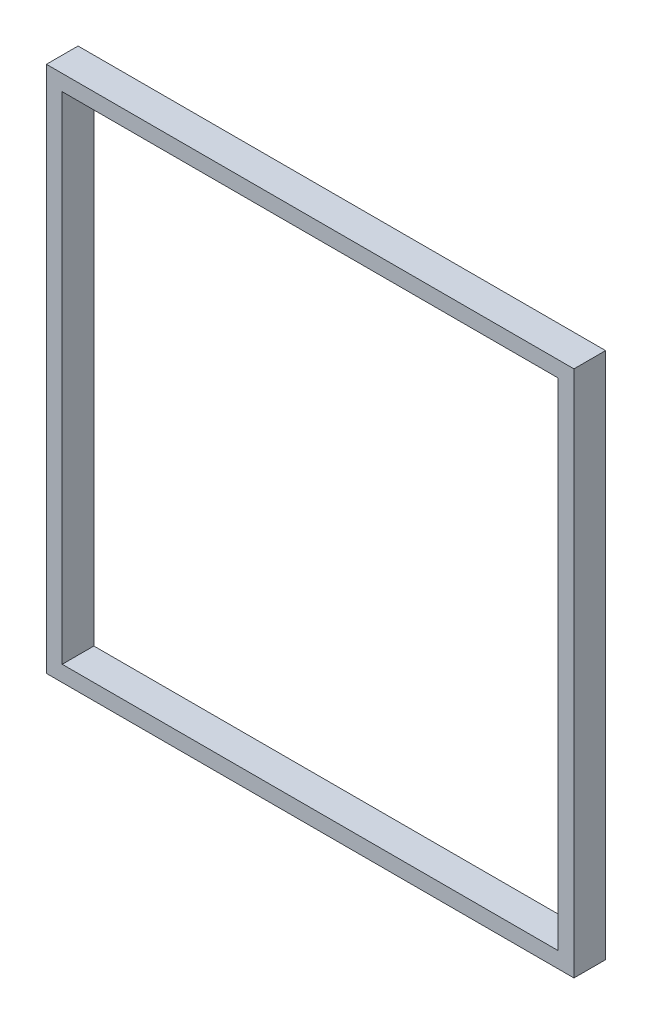
from build123d import *

# Parameters (mm, degrees)
SKETCH1_W           = 50
SKETCH1_H           = 50
SKETCH1_W_2         = 47
SKETCH1_H_2         = 47
BOSS_EXTRUDE1_DEPTH = 3


with BuildPart() as part:
    # Sketch1 → Boss-Extrude1 (new body)
    with BuildSketch(Plane.XY):
        with Locations((25, 25)):
            Rectangle(SKETCH1_W, SKETCH1_H)
        with Locations((25, 25)):
            Rectangle(SKETCH1_W_2, SKETCH1_H_2, mode=Mode.SUBTRACT)
    extrude(amount=BOSS_EXTRUDE1_DEPTH)


solid = part.part
